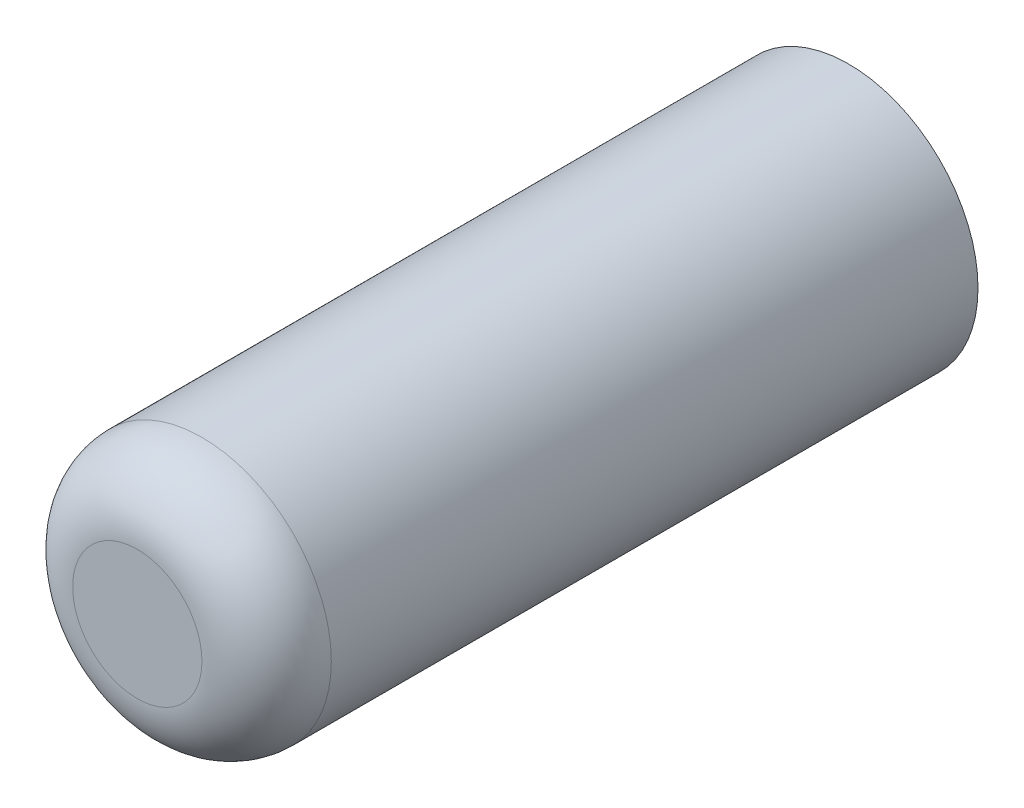
from build123d import *

# Parameters (mm, degrees)
SKIZZE1_R                       = 4
AUFSATZ_LINEAR_AUSTRAGEN1_DEPTH = 22
VERRUNDUNG1_R                   = 2


with BuildPart() as part:
    # Skizze1 → Aufsatz-Linear austragen1 (new body)
    with BuildSketch(Plane.XY):
        Circle(SKIZZE1_R)
    extrude(amount=AUFSATZ_LINEAR_AUSTRAGEN1_DEPTH)

    # Verrundung1
    verrundung1_edges = [part.edges().sort_by_distance(p)[0] for p in [
        (-4, 0, 22),
    ]]
    fillet(verrundung1_edges, radius=VERRUNDUNG1_R)


solid = part.part
